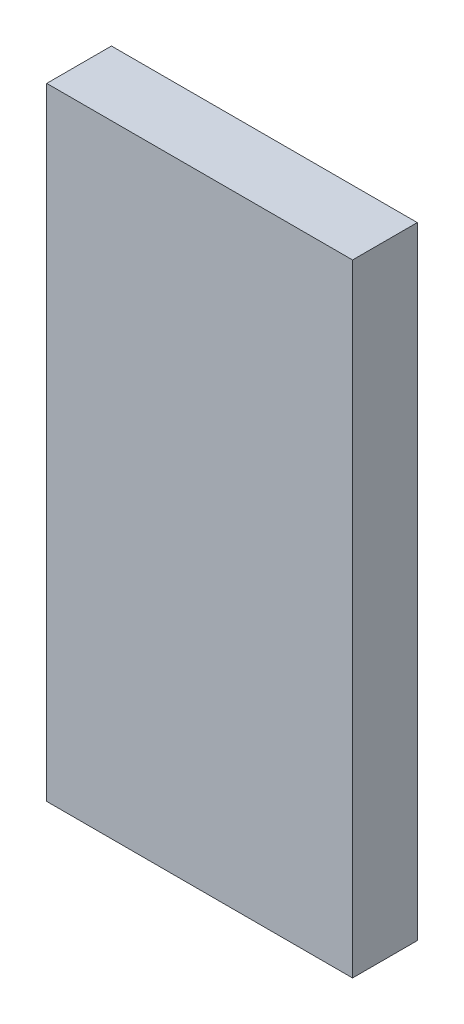
from build123d import *

# Parameters (mm, degrees)
SKETCH1_W           = 30
SKETCH1_H           = 61
BOSS_EXTRUDE1_DEPTH = 6.35


with BuildPart() as part:
    # Sketch1 → Boss-Extrude1 (new body)
    with BuildSketch(Plane.XY):
        with Locations((15, 30.5)):
            Rectangle(SKETCH1_W, SKETCH1_H)
    extrude(amount=BOSS_EXTRUDE1_DEPTH)


solid = part.part
